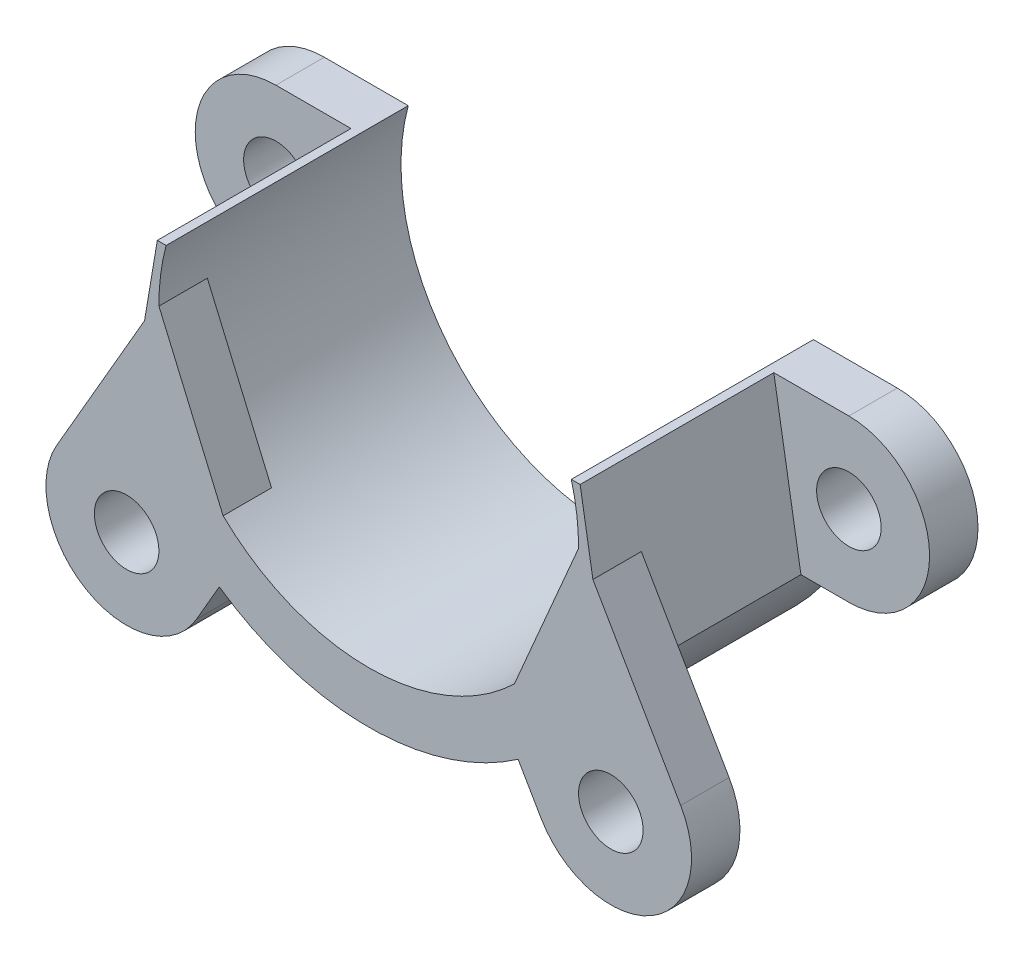
from build123d import *

# Parameters (mm, degrees)
ESBO_O1_R                = 2
RESSALTO_EXTRUS_O1_DEPTH = 3
RESSALTO_EXTRUS_O2_DEPTH = 12
ESBO_O3_R                = 2
RESSALTO_EXTRUS_O3_DEPTH = 3


with BuildPart() as part:
    # Esboço1 → Ressalto-extrusão1 (new body)
    with BuildSketch(Plane.XY):
        with BuildLine():
            Line((-17.75, 3.382927425), (-13.099117311, 3.382927425))
            Line((-13.099117311, 3.382927425), (-12.552123407, 3.382927425))
            ThreePointArc((-12.552123407, 3.382927425), (0, -13), (12.552123407, 3.382927425))
            Line((12.552123407, 3.382927425), (13.099117311, 3.382927425))
            Line((13.099117311, 3.382927425), (17.75, 3.382927425))
            ThreePointArc((17.75, 3.382927425), (22.75, -1.617072575), (17.75, -6.617072575))
            Line((17.75, -6.617072575), (14.779561157, -6.617072575))
            ThreePointArc((14.779561157, -6.617072575), (0, -16.193241721), (-14.779561157, -6.617072575))
            Line((-14.779561157, -6.617072575), (-17.75, -6.617072575))
            ThreePointArc((-17.75, -6.617072575), (-22.75, -1.617072575), (-17.75, 3.382927425))
        make_face()
        with Locations((-17.75, -1.617072575)):
            Circle(ESBO_O1_R, mode=Mode.SUBTRACT)
        with Locations((17.75, -1.617072575)):
            Circle(ESBO_O1_R, mode=Mode.SUBTRACT)
    extrude(amount=RESSALTO_EXTRUS_O1_DEPTH)

    # Esboço2 → Ressalto-extrusão2 (add)
    with BuildSketch(Plane.XY.offset(3)):
        with BuildLine():
            Line((13.099117311, 3.382927425), (14.779561157, -6.617072575))
            ThreePointArc((14.779561157, -6.617072575), (0, -16.193241721), (-14.779561157, -6.617072575))
            Line((-14.779561157, -6.617072575), (-13.099117311, 3.382927425))
            Line((-13.099117311, 3.382927425), (-12.552123407, 3.382927425))
            ThreePointArc((-12.552123407, 3.382927425), (0, -13), (12.552123407, 3.382927425))
            Line((12.552123407, 3.382927425), (13.099117311, 3.382927425))
        make_face()
    extrude(amount=RESSALTO_EXTRUS_O2_DEPTH)

    # Esboço3 → Ressalto-extrusão3 (add)
    with BuildSketch(Plane.XY.offset(15)):
        with BuildLine():
            Line((13.077187708, 0.083527365), (8.154782397, -11.379785765))
            Line((8.154782397, -11.379785765), (10.671688275, -15.731898104))
            ThreePointArc((10.671688275, -15.731898104), (17.503141549, -17.55706828), (19.328311725, -10.725615007))
            Line((19.328311725, -10.725615007), (13.077187708, 0.083527365))
        make_face()
        with Locations((15, -13.228756555)):
            Circle(ESBO_O3_R, mode=Mode.SUBTRACT)
        with BuildLine():
            Line((-10.671688275, -15.731898104), (-8.154782397, -11.379785765))
            Line((-8.154782397, -11.379785765), (-13.077187708, 0.083527365))
            Line((-13.077187708, 0.083527365), (-19.328311725, -10.725615007))
            ThreePointArc((-19.328311725, -10.725615007), (-17.503141549, -17.55706828), (-10.671688275, -15.731898104))
        make_face()
        with Locations((-15, -13.228756555)):
            Circle(ESBO_O3_R, mode=Mode.SUBTRACT)
    extrude(amount=-RESSALTO_EXTRUS_O3_DEPTH)


solid = part.part
